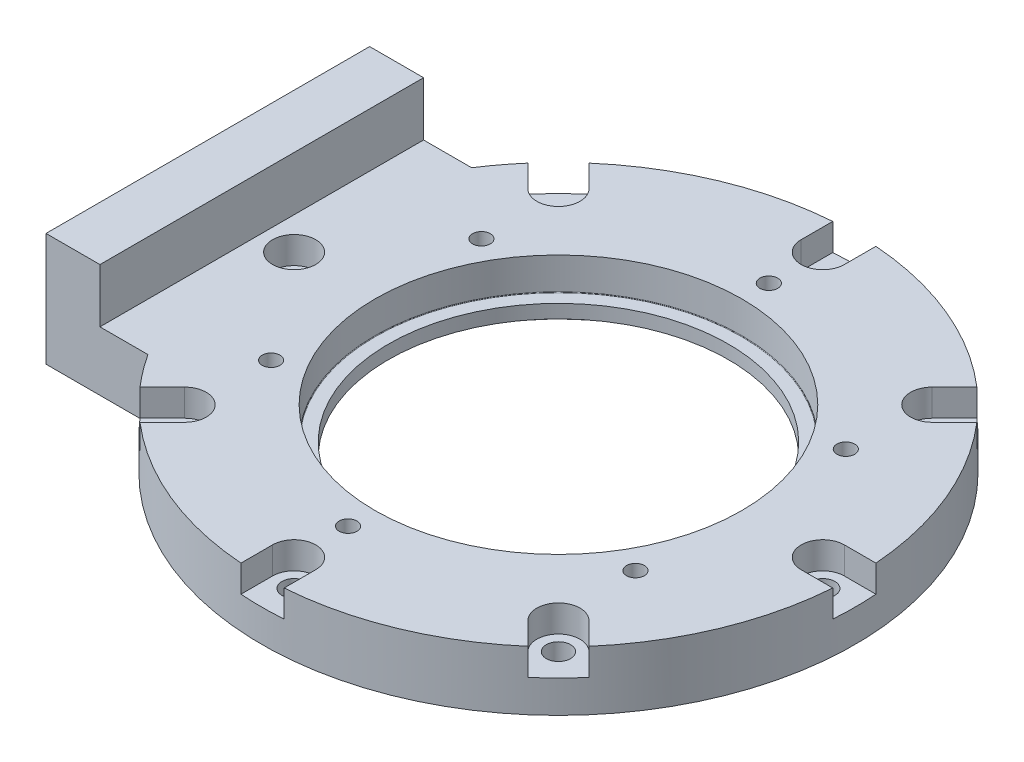
from build123d import *

# Parameters (mm, degrees)
SKETCH_1_R                   = 35
EXTRUDE_1_DEPTH              = 2.5
SKETCH_2_R                   = 31.5
EXTRUDE_2_DEPTH              = 2.5
SKETCH_3_R                   = 34
EXTRUDE_3_DEPTH              = 6
HOLE_WIZARD_M4_1_D           = 4.5
HOLE_WIZARD_M4_1_CBORE_D     = 8
HOLE_WIZARD_M4_1_CBORE_DEPTH = 5
HOLE_WIZARD_M4_1_2_D         = 3.3
PATTERN_CIRCULAR_1_COUNT     = 8
PATTERN_CIRCULAR_2_COUNT     = 6
SKETCH_11_W                  = 8
SKETCH_11_H                  = 12
CUT_EXTRUDE_1_DEPTH          = 5
SKETCH_12_W                  = 10
SKETCH_12_H                  = 60
EXTRUDE_4_DEPTH              = 10
SKETCH_13_W                  = 200
SKETCH_13_H                  = 130
CUT_EXTRUDE_2_DEPTH          = 12
PATTERN_CIRCULAR_3_COUNT     = 8
FILLET_1_R                   = 0.1


with BuildPart() as part:
    # 스케치1 → 보스-돌출1 (new body)
    with BuildSketch(Plane(origin=(0, 0, 0), x_dir=(1, 0, 0), z_dir=(0, 1, 0))):
        with BuildLine():
            Line((0, -55), (-65, -55))
            Line((-65, -55), (-65, 55))
            Line((-65, 55), (0, 55))
            ThreePointArc((0, 55), (55, 0), (0, -55))
        make_face()
        Circle(SKETCH_1_R, mode=Mode.SUBTRACT)
    extrude(amount=EXTRUDE_1_DEPTH)

    # 스케치2 → 보스-돌출2 (add)
    with BuildSketch(Plane(origin=(0, 2.5, 0), x_dir=(1, 0, 0), z_dir=(0, 1, 0))):
        with BuildLine():
            Line((-65, 55), (-65, -55))
            Line((-65, -55), (0, -55))
            ThreePointArc((0, -55), (55, 0), (0, 55))
            Line((0, 55), (-65, 55))
        make_face()
        Circle(SKETCH_2_R, mode=Mode.SUBTRACT)
    extrude(amount=EXTRUDE_2_DEPTH)

    # 스케치3 → 보스-돌출3 (add)
    with BuildSketch(Plane(origin=(0, 5, 0), x_dir=(1, 0, 0), z_dir=(0, 1, 0))):
        with BuildLine():
            Line((-65, 55), (-65, -55))
            Line((-65, -55), (0, -55))
            ThreePointArc((0, -55), (55, 0), (0, 55))
            Line((0, 55), (-65, 55))
        make_face()
        Circle(SKETCH_3_R, mode=Mode.SUBTRACT)
    extrude(amount=EXTRUDE_3_DEPTH)

    # Hole Wizard M4 _ _ _ _ _ _1 (through all)
    with Locations(Plane(origin=(0, 11, 0), x_dir=(1, 0, 0), z_dir=(0, 1, 0))):
        with Locations((0, 49)):
            hole_wizard_m4_1 = CounterBoreHole(HOLE_WIZARD_M4_1_D / 2, HOLE_WIZARD_M4_1_CBORE_D / 2, HOLE_WIZARD_M4_1_CBORE_DEPTH)

    # Hole Wizard M4 _ _ _ _1 2 (through all)
    with Locations(Plane(origin=(0, 11, 0), x_dir=(1, 0, 0), z_dir=(0, 1, 0))):
        with Locations((0, 39)):
            hole_wizard_m4_1_2 = Hole(HOLE_WIZARD_M4_1_2_D / 2)

    # 원형 패턴1: Hole Wizard M4 _ _ _ _ _ _1 ×8 about axis
    pattern_circular_1_axis = Axis((0, 0, 0), (0, 1, 0))
    for i in range(1, PATTERN_CIRCULAR_1_COUNT):
        add(hole_wizard_m4_1.rotate(pattern_circular_1_axis, i * 360 / PATTERN_CIRCULAR_1_COUNT), mode=Mode.SUBTRACT)

    # 원형 패턴2: Hole Wizard M4 _ _ _ _1 2 ×6 about axis
    pattern_circular_2_axis = Axis((0, 0, 0), (0, 1, 0))
    for i in range(1, PATTERN_CIRCULAR_2_COUNT):
        add(hole_wizard_m4_1_2.rotate(pattern_circular_2_axis, i * 360 / PATTERN_CIRCULAR_2_COUNT), mode=Mode.SUBTRACT)

    # 스케치11 → 컷-돌출1 (cut, symmetric)
    with BuildSketch(Plane(origin=(0, 11, 0), x_dir=(1, 0, 0), z_dir=(0, 1, 0))):
        with Locations((0, 55)):
            Rectangle(SKETCH_11_W, SKETCH_11_H)
    cut_extrude_1 = extrude(amount=CUT_EXTRUDE_1_DEPTH, both=True, mode=Mode.SUBTRACT)

    # 스케치12 → 보스-돌출4 (add)
    with BuildSketch(Plane(origin=(0, 11, 0), x_dir=(1, 0, 0), z_dir=(0, 1, 0))):
        with Locations((-60, 0)):
            Rectangle(SKETCH_12_W, SKETCH_12_H)
    extrude(amount=EXTRUDE_4_DEPTH)

    # 스케치13 → 컷-돌출2 (cut, through all)
    with BuildSketch(Plane(origin=(0, 11, 0), x_dir=(1, 0, 0), z_dir=(0, 1, 0))):
        Rectangle(SKETCH_13_W, SKETCH_13_H)
        with BuildLine():
            Line((-65, -30), (-46.097722286, -30))
            ThreePointArc((-46.097722286, -30), (55, 0), (-46.097722286, 30))
            Line((-46.097722286, 30), (-65, 30))
            Line((-65, 30), (-65, -30))
        make_face(mode=Mode.SUBTRACT)
    extrude(amount=-CUT_EXTRUDE_2_DEPTH, mode=Mode.SUBTRACT)

    # 원형 패턴3: 컷-돌출1 ×8 about axis, 1 skipped
    pattern_circular_3_axis = Axis((0, 0, 0), (0, 1, 0))
    add([cut_extrude_1.rotate(pattern_circular_3_axis, i * 360 / PATTERN_CIRCULAR_3_COUNT) for i in range(1, PATTERN_CIRCULAR_3_COUNT) if i not in (2,)], mode=Mode.SUBTRACT)

    # 필렛1
    fillet_1_edges = [part.edges().sort_by_distance(p)[0] for p in [
        (-35, 2.5, 0),
        (-34, 5, 0),
    ]]
    fillet(fillet_1_edges, radius=FILLET_1_R)


solid = part.part
